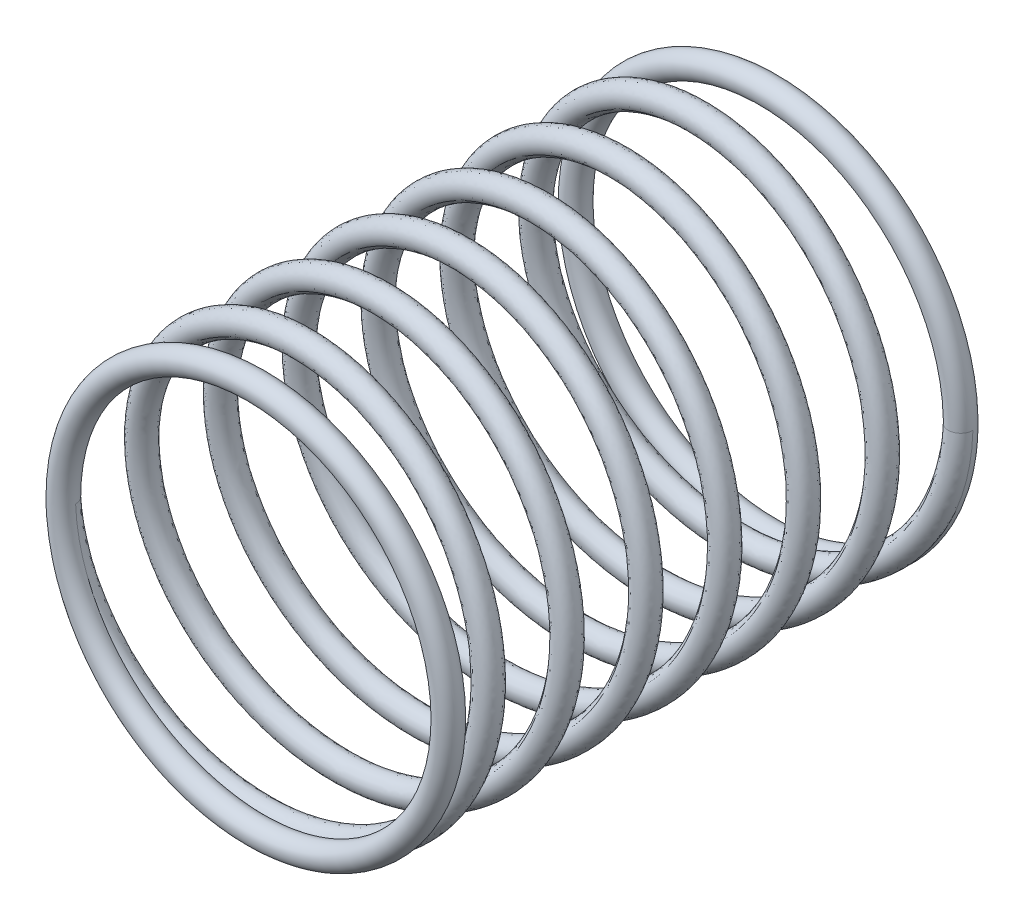
from build123d import *

# Parameters (mm, degrees)
T_HNOUT_PO_K_IVCE1_PITCH  = 5.138461538
T_HNOUT_PO_K_IVCE1_HEIGHT = 33.4
T_HNOUT_PO_K_IVCE1_RADIUS = 12.55
SKICA4_R                  = 0.8
SKICA5_R                  = 0.8


with BuildPart() as part:
    # T_hnout po k_ivce1: sweep along a helix
    with BuildLine() as t_hnout_po_k_ivce1_path:
        Helix(T_HNOUT_PO_K_IVCE1_PITCH, T_HNOUT_PO_K_IVCE1_HEIGHT, T_HNOUT_PO_K_IVCE1_RADIUS, center=(0, 0, 0.8), direction=(0, 0, 1), lefthand=True)
    # Skica4 → T_hnout po k_ivce1 (sweep)
    with BuildSketch(Plane(origin=(0, 0, 0), x_dir=(1, 0, 0), z_dir=(0, 1, 0))):
        with Locations((12.55, -0.8)):
            Circle(SKICA4_R)
    sweep(path=t_hnout_po_k_ivce1_path.line, is_frenet=True)

    # Skica5 → Rotovat1 (revolve)
    with BuildSketch(Plane(origin=(0, 0, 0), x_dir=(1, 0, 0), z_dir=(0, 1, 0)), mode=Mode.PRIVATE) as rotovat1_sk:
        with Locations((-12.55, -34.2)):
            Circle(SKICA5_R)
        with Locations((12.55, -0.8)):
            Circle(SKICA5_R)
    revolve(rotovat1_sk.sketch.rotate(Axis((0, 0, 0), (0, 0, -1)), 55.908961062), axis=Axis((0, 0, 0), (0, 0, -1)))


solid = part.part
